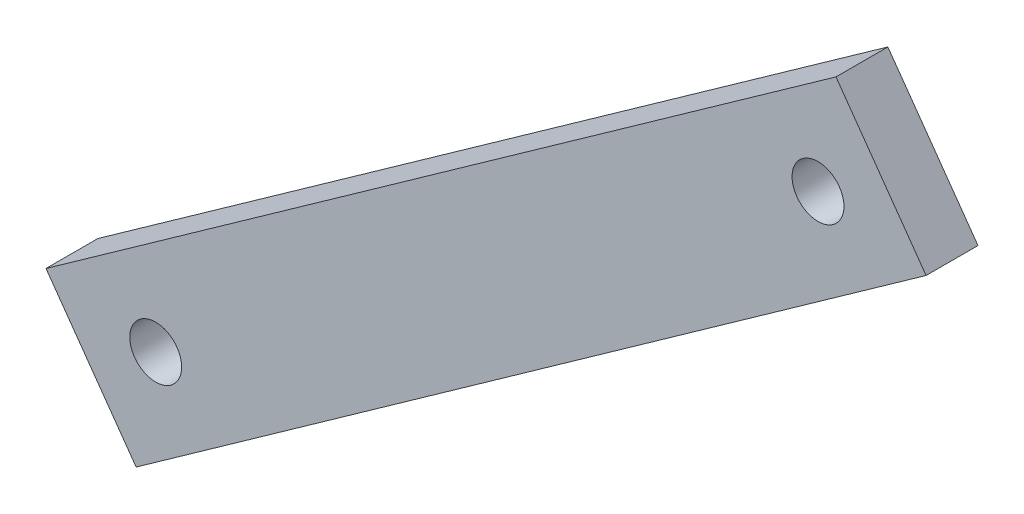
from build123d import *

# Parameters (mm, degrees)
BOSS_EXTRUDE1_DEPTH = 2.54
SKETCH1_4_R         = 1.27
CUT_EXTRUDE1_DEPTH  = 3.302


with BuildPart() as part:
    # Sketch1 → Boss-Extrude1 (new body)
    with BuildSketch(Plane.XY):
        Polygon((-67.806668191, 8.452347061), (-29.139739371, 35.905866523), (-24.728354348, 29.69264818), (-63.395283168, 2.239128718), align=None)
    extrude(amount=BOSS_EXTRUDE1_DEPTH)

    # Sketch1_4 → Cut-Extrude1 (cut)
    with BuildSketch(Plane.XY):
        with Locations((-62.437432462, 7.591853574)):
            Circle(SKETCH1_4_R)
        with Locations((-30.019544177, 30.608554257)):
            Circle(SKETCH1_4_R)
    extrude(amount=CUT_EXTRUDE1_DEPTH, mode=Mode.SUBTRACT)


solid = part.part
